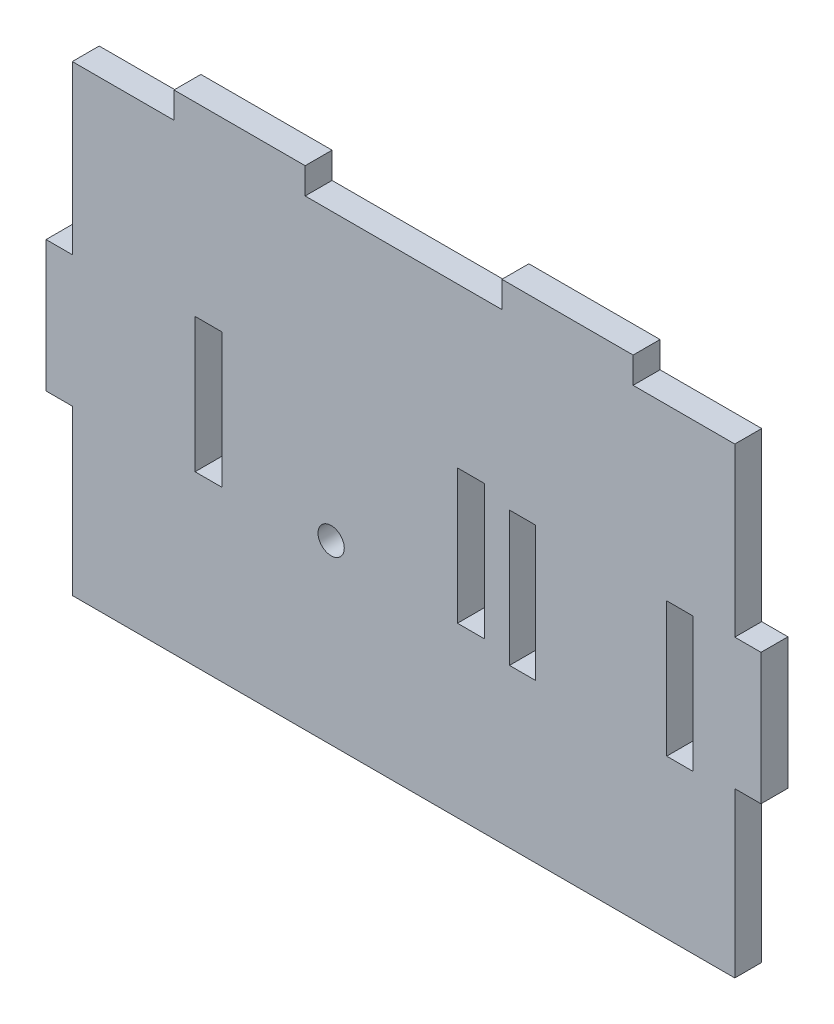
from build123d import *

# Parameters (mm, degrees)
CROQUIS1_R              = 1.949957096
CROQUIS1_W              = 3.899914193
CROQUIS1_H              = 20
CROQUIS1_W_2            = 3.931890122
SALIENTE_EXTRUIR1_DEPTH = 4
CROQUIS3_W              = 4
CROQUIS3_H              = 20
CORTAR_EXTRUIR2_DEPTH   = 18


with BuildPart() as part:
    # Croquis1 → Saliente-Extruir1 (new body)
    with BuildSketch(Plane.XY):
        Polygon((1.526053109, 36.234397526), (1.526053109, 45.984183007), (5.425967302, 45.984183007), (5.425967302, 70.846135986), (20.538134799, 70.846135986), (20.538134799, 74.746050179), (40.037705762, 74.746050179), (40.037705762, 70.846135986), (69.287062208, 70.846135986), (69.287062208, 74.746050179), (88.786633171, 74.746050179), (88.786633171, 70.846135986), (103.898800668, 70.846135986), (103.898800668, 45.984183007), (107.798714861, 45.984183007), (107.798714861, 36.234397526), (107.798714861, 26.484612044), (103.898800668, 26.484612044), (103.898800668, 2.110148339), (5.425967302, 2.110148339), (5.425967302, 26.484612044), (1.526053109, 26.484612044), align=None)
        with Locations((43.902907702, 28.411154562)):
            Circle(CROQUIS1_R, mode=Mode.SUBTRACT)
        with Locations((72.35718349, 35.603908164)):
            Rectangle(CROQUIS1_W, CROQUIS1_H, mode=Mode.SUBTRACT)
        with Locations((95.740680681, 35.603908164)):
            Rectangle(CROQUIS1_W_2, CROQUIS1_H, mode=Mode.SUBTRACT)
    extrude(amount=SALIENTE_EXTRUIR1_DEPTH)

    # Croquis3 → Cortar-Extruir2 (cut)
    with BuildSketch(Plane.XY.offset(4)):
        with Locations((64.674115468, 37.164302326)):
            Rectangle(CROQUIS3_W, CROQUIS3_H)
        with Locations((25.674115468, 37.164302326)):
            Rectangle(CROQUIS3_W, CROQUIS3_H)
    extrude(amount=-CORTAR_EXTRUIR2_DEPTH, mode=Mode.SUBTRACT)


solid = part.part
